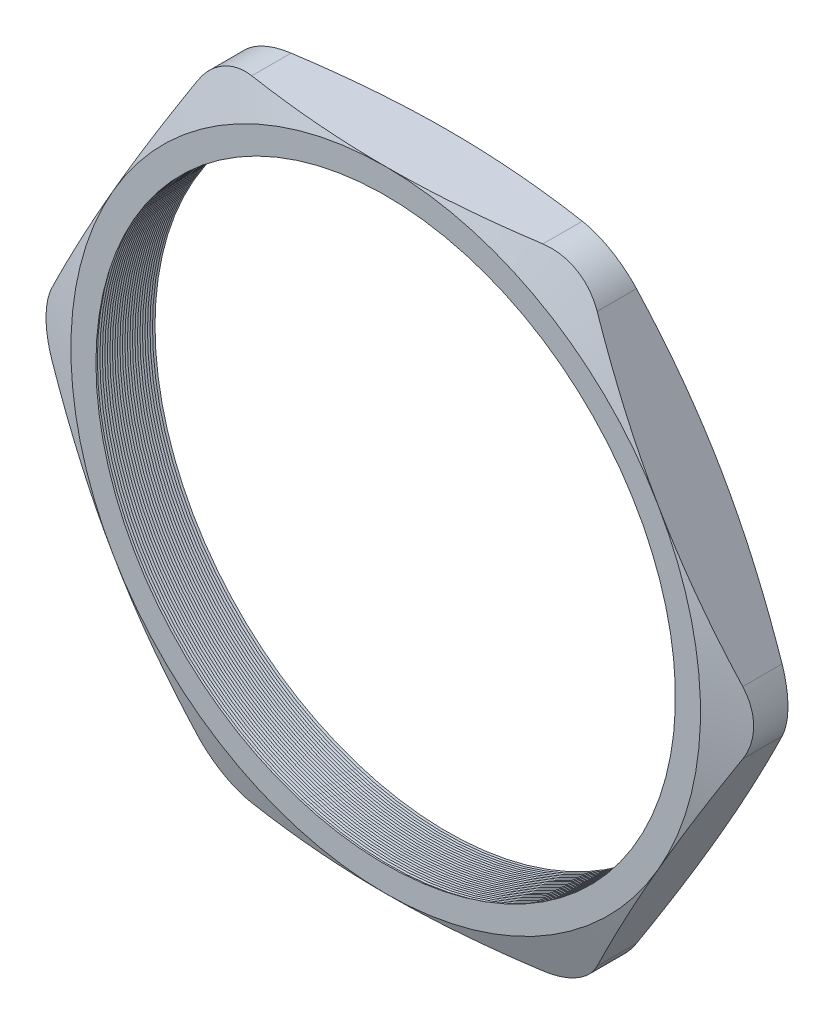
from build123d import *

# Parameters (mm, degrees)
SKETCH1_R          = 23.495
EXTRUDE1_DEPTH     = 5.08
FILLET1_R          = 5.08
SKETCH2_OUTSIDE_W  = 108.184
SKETCH2_OUTSIDE_H  = 101.858
SKETCH2_OUTSIDE_R  = 25.527
CUT_EXTRUDE1_DEPTH = 6.08
CUT_EXTRUDE1_DRAFT = -70
SKETCH3_OUTSIDE_W  = 108.184
SKETCH3_OUTSIDE_H  = 101.858
SKETCH3_OUTSIDE_R  = 25.527
CUT_EXTRUDE2_DEPTH = 6.0800001
CUT_EXTRUDE2_DRAFT = -70
LPATTERN1_COUNT    = 25
LPATTERN1_PITCH    = 0.2032


with BuildPart() as part:
    # Sketch1 → Extrude1 (new body)
    with BuildSketch(Plane.XY):
        Polygon((-29.476040643, 0), (-14.738020322, -25.527), (14.738020322, -25.527), (29.476040643, 0), (14.738020322, 25.527), (-14.738020322, 25.527), align=None)
        Circle(SKETCH1_R, mode=Mode.SUBTRACT)
    extrude(amount=EXTRUDE1_DEPTH)

    # Fillet1
    fillet1_edges = [part.edges().sort_by_distance(p)[0] for p in [
        (29.476040643, 0, 2.54),
        (14.738020322, -25.527, 2.54),
        (-14.738020322, -25.527, 2.54),
        (-29.476040643, 0, 2.54),
        (-14.738020322, 25.527, 2.54),
        (14.738020322, 25.527, 2.54),
    ]]
    fillet(fillet1_edges, radius=FILLET1_R)


with BuildPart() as cut_extrude1_tool:
    # Sketch2 outside → Cut-Extrude1 (with draft: the straight prism first)
    with BuildSketch(Plane.XY.offset(5.08)):
        Rectangle(SKETCH2_OUTSIDE_W, SKETCH2_OUTSIDE_H)
        Circle(SKETCH2_OUTSIDE_R, mode=Mode.SUBTRACT)
    extrude(amount=-CUT_EXTRUDE1_DEPTH)
    # Cut-Extrude1: the draft: its side faces are tilted about the plane it starts from
    cut_extrude1_sides = [cut_extrude1_tool.faces().sort_by_distance(p)[0] for p in [
        (0, -50.929, 2.04),
        (54.092, 0, 2.04),
        (0, 50.929, 2.04),
        (-54.092, 0, 2.04),
        (-25.527, 0, 2.04),
    ]]
    draft(cut_extrude1_sides, Plane.XY.offset(5.08), CUT_EXTRUDE1_DRAFT)


with BuildPart() as part_1:
    add(part.part)

    # Cut-Extrude1: cut by cut_extrude1_tool
    add(cut_extrude1_tool.part, mode=Mode.SUBTRACT)


with BuildPart() as cut_extrude2_tool:
    # Sketch3 outside → Cut-Extrude2 (with draft: the straight prism first)
    with BuildSketch(Plane(origin=(0, 0, 0), x_dir=(-1, 0, 0), z_dir=(0, 0, -1))):
        Rectangle(SKETCH3_OUTSIDE_W, SKETCH3_OUTSIDE_H)
        Circle(SKETCH3_OUTSIDE_R, mode=Mode.SUBTRACT)
    extrude(amount=-CUT_EXTRUDE2_DEPTH)
    # Cut-Extrude2: the draft: its side faces are tilted about the plane it starts from
    cut_extrude2_sides = [cut_extrude2_tool.faces().sort_by_distance(p)[0] for p in [
        (0, -50.929, 3.04000005),
        (-54.092, 0, 3.04000005),
        (0, 50.929, 3.04000005),
        (54.092, 0, 3.04000005),
        (25.527, 0, 3.04000005),
    ]]
    draft(cut_extrude2_sides, Plane(origin=(0, 0, 0), x_dir=(-1, 0, 0), z_dir=(0, 0, -1)), CUT_EXTRUDE2_DRAFT)


with BuildPart() as part_2:
    add(part_1.part)

    # Cut-Extrude2: cut by cut_extrude2_tool
    add(cut_extrude2_tool.part, mode=Mode.SUBTRACT)

    # Sketch4 → Cut-Revolve1 (revolve, cut)
    with BuildSketch(Plane(origin=(0, 0, 0), x_dir=(1, 0, 0), z_dir=(0, 1, 0))):
        Polygon((-23.495, -5.08), (-23.495, -4.640059095), (-23.876, -4.860029547), align=None)
    cut_revolve1 = revolve(axis=Axis((0, 0, 5.08), (0, 0, -1)), mode=Mode.SUBTRACT)

    # LPattern1: Cut-Revolve1 ×25
    with Locations(*[(0, 0, -i * LPATTERN1_PITCH) for i in range(1, LPATTERN1_COUNT)]):
        add(cut_revolve1, mode=Mode.SUBTRACT)


solid = part_2.part
